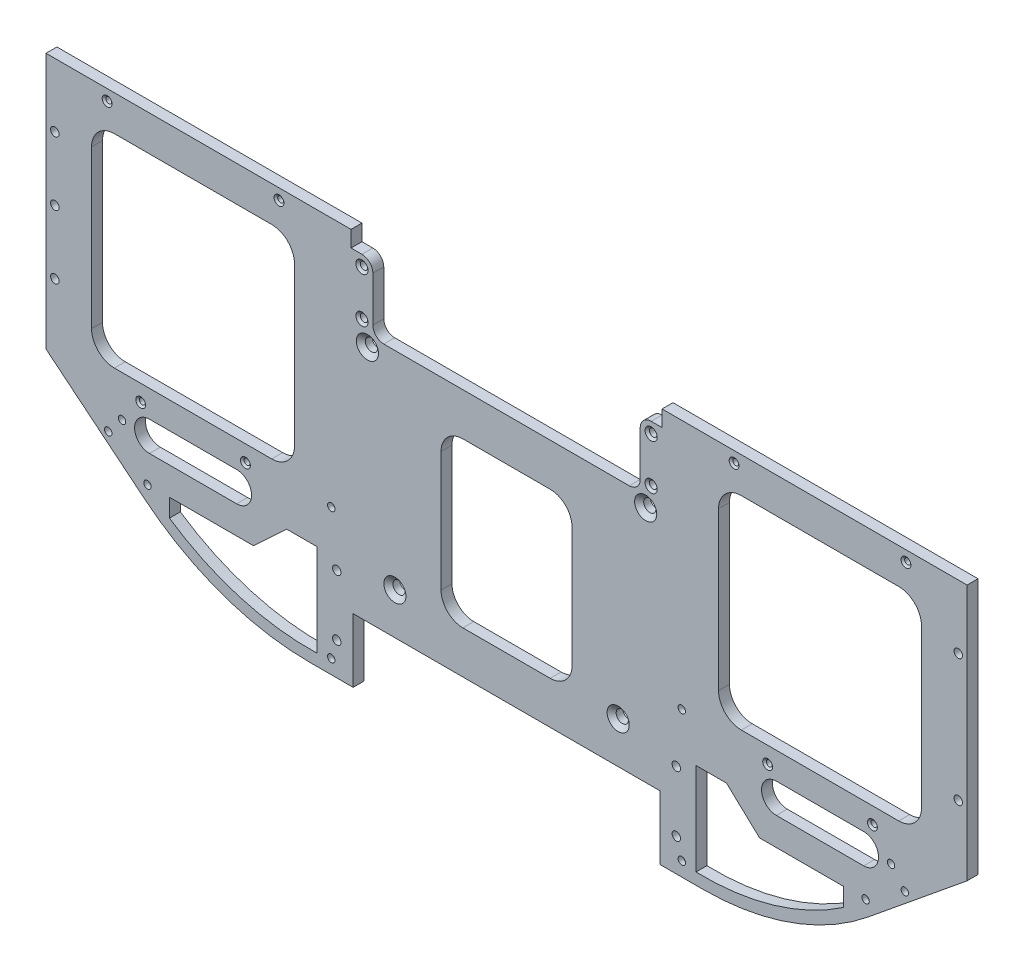
from build123d import *

# Parameters (mm, degrees)
BOSS_EXTRUDE1_DEPTH                                 = 6.35
CUT_EXTRUDE1_DEPTH                                  = 7.35
CSK_FOR_1_4_FLAT_HEAD_MACHINE_SCREW_100_D           = 7.14248
CSK_FOR_1_4_FLAT_HEAD_MACHINE_SCREW_100_DEPTH       = 6.35
CSK_FOR_1_4_FLAT_HEAD_MACHINE_SCREW_100_CSINK_D     = 12.8778
CSK_FOR_1_4_FLAT_HEAD_MACHINE_SCREW_100_CSINK_ANGLE = 100
CSK_FOR_4_FLAT_HEAD_MACHINE_SCREW_100_D             = 3.4544
CSK_FOR_4_FLAT_HEAD_MACHINE_SCREW_100_CSINK_D       = 5.715
CSK_FOR_4_FLAT_HEAD_MACHINE_SCREW_100_CSINK_ANGLE   = 100
CUT_EXTRUDE2_REACH                                  = 8.35
SKETCH7_W                                           = 178.5366
SKETCH7_H                                           = 37.1475
F_6_CLEARANCE_HOLE1_D                               = 4.3053
F_6_CLEARANCE_HOLE1_DEPTH                           = 6.35
F_6_PLASTIC_INSERT_AT_2_COUNT                       = 2
F_6_PLASTIC_INSERT_AT_2_PITCH                       = 112.229639339
F_6_PLASTIC_INSERT_AT_3_COUNT                       = 2
F_6_PLASTIC_INSERT_AT_3_PITCH                       = 114.9605422
F_6_PLASTIC_INSERT_AT_4_COUNT                       = 2
F_6_PLASTIC_INSERT_AT_4_PITCH                       = 313.747300742
F_6_PLASTIC_INSERT_AT_5_COUNT                       = 2
F_6_PLASTIC_INSERT_AT_5_PITCH                       = 312.75698938
F_6_PLASTIC_INSERT_AT_6_COUNT                       = 2
F_6_PLASTIC_INSERT_AT_6_PITCH                       = 417.83
F_6_CLEARANCE_HOLE2_D                               = 4.3053
CUT_EXTRUDE3_REACH                                  = 8.35
SKETCH55_W                                          = 12.7
SKETCH55_H                                          = 26.162975929
BOSS_EXTRUDE2_DEPTH                                 = 6.35
FILLET3_R                                           = 6.35
CSK_FOR_6_FLAT_HEAD_MACHINE_SCREW_100_D             = 4.3053
CSK_FOR_6_FLAT_HEAD_MACHINE_SCREW_100_CSINK_D       = 7.0866
CSK_FOR_6_FLAT_HEAD_MACHINE_SCREW_100_CSINK_ANGLE   = 100
SKETCH58_W                                          = 76.2
SKETCH58_H                                          = 95.25
CUT_EXTRUDE4_DEPTH                                  = 7.35
CUT_EXTRUDE5_DEPTH                                  = 7.35
CSK_FOR_8_FLAT_HEAD_MACHINE_SCREW_100_D             = 4.9149
CSK_FOR_8_FLAT_HEAD_MACHINE_SCREW_100_DEPTH         = 6.35
CSK_FOR_8_FLAT_HEAD_MACHINE_SCREW_100_CSINK_D       = 8.4328
CSK_FOR_8_FLAT_HEAD_MACHINE_SCREW_100_CSINK_ANGLE   = 100
FILLET4_R                                           = 12.7
CSK_FOR_6_FLAT_HEAD_MACHINE_SCREW_2_D               = 4.3053
CSK_FOR_6_FLAT_HEAD_MACHINE_SCREW_2_DEPTH           = 6.35
CSK_FOR_6_FLAT_HEAD_MACHINE_SCREW_2_CSINK_D         = 7.0866
CSK_FOR_6_FLAT_HEAD_MACHINE_SCREW_2_CSINK_ANGLE     = 100


with BuildPart() as part:
    # Sketch1 → Boss-Extrude1 (new body)
    with BuildSketch(Plane.XY):
        with BuildLine():
            Line((-296.70375, -233.3625), (-68.10375, -233.3625))
            ThreePointArc((-68.10375, -233.3625), (-16.943813494, -224.518833531), (28.278571633, -199.014217805))
            Line((28.278571633, -199.014217805), (95.09125, -144.4625))
            ThreePointArc((95.09125, -144.4625), (116.399773511, -117.921148224), (131.28625, -87.3125))
            Line((131.28625, -87.3125), (131.28625, 23.8125))
            Line((131.28625, 23.8125), (85.56625, 23.8125))
            Line((85.56625, 23.8125), (85.56625, -3.175))
            Line((85.56625, -3.175), (-131.60375, -3.175))
            Line((-131.60375, -3.175), (-131.60375, 20.5105))
            Line((-131.60375, 20.5105), (-233.20375, 20.5105))
            Line((-233.20375, 20.5105), (-233.20375, -3.175))
            Line((-233.20375, -3.175), (-450.37375, -3.175))
            Line((-450.37375, -3.175), (-450.37375, -20.955))
            Line((-450.37375, -20.955), (-496.09375, -20.955))
            Line((-496.09375, -20.955), (-496.09375, -87.3125))
            ThreePointArc((-496.09375, -87.3125), (-481.207273511, -117.921148224), (-459.89875, -144.4625))
            Line((-459.89875, -144.4625), (-393.086071633, -199.014217805))
            ThreePointArc((-393.086071633, -199.014217805), (-347.863686506, -224.518833531), (-296.70375, -233.3625))
        make_face()
    extrude(amount=BOSS_EXTRUDE1_DEPTH)

    # Sketch2 → Cut-Extrude1 (cut, through all)
    with BuildSketch(Plane.XY.offset(6.35)):
        with BuildLine():
            Line((-423.8625, -37.078640371), (-423.8625, -128.656359629))
            ThreePointArc((-423.8625, -128.656359629), (-419.976937445, -138.036937445), (-410.596359629, -141.9225))
            Line((-410.596359629, -141.9225), (-319.018640371, -141.9225))
            ThreePointArc((-319.018640371, -141.9225), (-309.638062555, -138.036937445), (-305.7525, -128.656359629))
            Line((-305.7525, -128.656359629), (-305.7525, -37.078640371))
            ThreePointArc((-305.7525, -37.078640371), (-309.638062555, -27.698062555), (-319.018640371, -23.8125))
            Line((-319.018640371, -23.8125), (-410.596359629, -23.8125))
            ThreePointArc((-410.596359629, -23.8125), (-419.976937445, -27.698062555), (-423.8625, -37.078640371))
        make_face()
        with BuildLine():
            Line((-292.63975, -172.976918908), (-292.63975, -226.638323184))
            ThreePointArc((-292.63975, -226.638323184), (-337.571759927, -220.847335922), (-378.554315308, -201.537980571))
            Line((-378.554315308, -201.537980571), (-378.554315308, -190.97625))
            Line((-378.554315308, -190.97625), (-329.636065959, -190.97625))
            Line((-329.636065959, -190.97625), (-310.347063169, -172.976918908))
            Line((-310.347063169, -172.976918908), (-292.63975, -172.976918908))
        make_face()
        with BuildLine():
            Line((-339.407500187, -174.752000205), (-390.207500187, -174.752000205))
            ThreePointArc((-390.207500187, -174.752000205), (-398.843500187, -166.116000205), (-390.207500187, -157.480000205))
            Line((-390.207500187, -157.480000205), (-339.407500187, -157.480000205))
            ThreePointArc((-339.407500187, -157.480000205), (-330.771500187, -166.116000205), (-339.407500187, -174.752000205))
        make_face()
        with BuildLine():
            Line((-25.399999813, -174.752000205), (25.400000187, -174.752000205))
            ThreePointArc((25.400000187, -174.752000205), (34.036000187, -166.116000205), (25.400000187, -157.480000205))
            Line((25.400000187, -157.480000205), (-25.399999813, -157.480000205))
            ThreePointArc((-25.399999813, -157.480000205), (-34.035999813, -166.116000205), (-25.399999813, -174.752000205))
        make_face()
        with BuildLine():
            Line((13.746815308, -201.537980571), (13.746815308, -190.97625))
            Line((13.746815308, -190.97625), (-35.171434041, -190.97625))
            Line((-35.171434041, -190.97625), (-54.460436831, -172.976918908))
            Line((-54.460436831, -172.976918908), (-72.16775, -172.976918908))
            Line((-72.16775, -172.976918908), (-72.16775, -226.638323184))
            ThreePointArc((-72.16775, -226.638323184), (-27.235740073, -220.847335922), (13.746815308, -201.537980571))
        make_face()
        with BuildLine():
            Line((45.788859629, -141.9225), (-45.788859629, -141.9225))
            ThreePointArc((-45.788859629, -141.9225), (-55.169437445, -138.036937445), (-59.055, -128.656359629))
            Line((-59.055, -128.656359629), (-59.055, -37.078640371))
            ThreePointArc((-59.055, -37.078640371), (-55.169437445, -27.698062555), (-45.788859629, -23.8125))
            Line((-45.788859629, -23.8125), (45.788859629, -23.8125))
            ThreePointArc((45.788859629, -23.8125), (55.169437445, -27.698062555), (59.055, -37.078640371))
            Line((59.055, -37.078640371), (59.055, -128.656359629))
            ThreePointArc((59.055, -128.656359629), (55.169437445, -138.036937445), (45.788859629, -141.9225))
        make_face()
    extrude(amount=-CUT_EXTRUDE1_DEPTH, mode=Mode.SUBTRACT)

    # CSK for 1/4 Flat Head Machine Screw (100)1
    with Locations(Plane.XY.offset(6.35)):
        with Locations((-247.36425, -172.085), (-263.36625, -57.785), (-117.44325, -172.085), (-101.44125, -57.785)):
            CounterSinkHole(CSK_FOR_1_4_FLAT_HEAD_MACHINE_SCREW_100_D / 2, CSK_FOR_1_4_FLAT_HEAD_MACHINE_SCREW_100_CSINK_D / 2, depth=CSK_FOR_1_4_FLAT_HEAD_MACHINE_SCREW_100_DEPTH, counter_sink_angle=CSK_FOR_1_4_FLAT_HEAD_MACHINE_SCREW_100_CSINK_ANGLE)

    # CSK for #4 Flat Head Machine Screw (100)1 (through all)
    with Locations(Plane.XY.offset(6.35)):
        with Locations((-334.327500124, -151.530549932), (-395.287499843, -151.53054989), (-314.801250003, -9.525000088), (-414.813749771, -9.52500002), (30.479999876, -151.530549932), (-30.479999843, -151.53054989), (50.006249997, -9.525000088), (-50.006249771, -9.52500002)):
            CounterSinkHole(CSK_FOR_4_FLAT_HEAD_MACHINE_SCREW_100_D / 2, CSK_FOR_4_FLAT_HEAD_MACHINE_SCREW_100_CSINK_D / 2, counter_sink_angle=CSK_FOR_4_FLAT_HEAD_MACHINE_SCREW_100_CSINK_ANGLE)

    # Sketch7 → Cut-Extrude2 (cut, up to next)
    with BuildSketch(Plane.XY.offset(6.35), mode=Mode.PRIVATE) as cut_extrude2_sk1:
        with Locations((-182.40375, -214.78875)):
            Rectangle(SKETCH7_W, SKETCH7_H)
    cut_extrude2_tool1 = extrude(cut_extrude2_sk1.sketch, amount=-CUT_EXTRUDE2_REACH, mode=Mode.PRIVATE) & part.part
    add(cut_extrude2_tool1.solids().sort_by_distance((-182.40375, -214.78875, 6.35))[0], mode=Mode.SUBTRACT)

    # #6 Clearance Hole1
    with Locations(Plane(origin=(-452.317147347, -175.564262538, 0), x_dir=(-1, 0, 0), z_dir=(0, 0, -1))):
        with Locations((-60.998397348, -15.475487462), (-167.932397348, -49.543237462), (-167.932397348, 26.726952124), (-371.894397347, 26.726952124), (-371.894397347, -49.543237462), (-478.828397347, -15.475487462)):
            Hole(F_6_CLEARANCE_HOLE1_D / 2, depth=F_6_CLEARANCE_HOLE1_DEPTH)

    # Sketch51 → #6 Plastic Insert (revolve, cut)
    with BuildSketch(Plane(origin=(-391.31875, -191.03975, 0), x_dir=(0, 1, 0), z_dir=(1, 0, 0))):
        Polygon((0, 0), (0, 3.81), (2.5273, 3.81), (2.6543, 0), align=None)
    f_6_plastic_insert = revolve(axis=Axis((-391.31875, -191.03975, 110), (0, 0, -1)), mode=Mode.SUBTRACT)

    # #6 Plastic Insert at 2: #6 Plastic Insert ×2
    with Locations(*[Vector(0.952814253, -0.303553947, 0) * (i * F_6_PLASTIC_INSERT_AT_2_PITCH) for i in range(1, F_6_PLASTIC_INSERT_AT_2_COUNT)]):
        add(f_6_plastic_insert, mode=Mode.SUBTRACT)

    # #6 Plastic Insert at 3: #6 Plastic Insert ×2
    with Locations(*[Vector(0.930180025, 0.367103693, 0) * (i * F_6_PLASTIC_INSERT_AT_3_PITCH) for i in range(1, F_6_PLASTIC_INSERT_AT_3_COUNT)]):
        add(f_6_plastic_insert, mode=Mode.SUBTRACT)

    # #6 Plastic Insert at 4: #6 Plastic Insert ×2
    with Locations(*[Vector(0.990912111, 0.134510925, 0) * (i * F_6_PLASTIC_INSERT_AT_4_PITCH) for i in range(1, F_6_PLASTIC_INSERT_AT_4_COUNT)]):
        add(f_6_plastic_insert, mode=Mode.SUBTRACT)

    # #6 Plastic Insert at 5: #6 Plastic Insert ×2
    with Locations(*[Vector(0.994049727, -0.108927222, 0) * (i * F_6_PLASTIC_INSERT_AT_5_PITCH) for i in range(1, F_6_PLASTIC_INSERT_AT_5_COUNT)]):
        add(f_6_plastic_insert, mode=Mode.SUBTRACT)

    # #6 Plastic Insert at 6: #6 Plastic Insert ×2
    with Locations(*[(i * F_6_PLASTIC_INSERT_AT_6_PITCH, 0, 0) for i in range(1, F_6_PLASTIC_INSERT_AT_6_COUNT)]):
        add(f_6_plastic_insert, mode=Mode.SUBTRACT)

    # #6 Clearance Hole2 (through all)
    with Locations(Plane(origin=(0, 0, 0), x_dir=(-1, 0, 0), z_dir=(0, 0, -1))):
        with Locations((459.51775, -126.1745), (479.90125, -91.8845), (486.50525, -36.449), (-94.71025, -126.1745), (-121.95175, -83.6295), (-98.26625, 15.875)):
            Hole(F_6_CLEARANCE_HOLE2_D / 2)

    # Sketch54 → Cut-Extrude3 (cut, up to next)
    with BuildSketch(Plane.XY.offset(6.35), mode=Mode.PRIVATE) as cut_extrude3_sk1:
        Polygon((-272.89125, -38.735), (-260.19125, -38.735), (-260.19125, -51.435), (-104.61625, -51.435), (-104.61625, -38.735), (-91.91625, -38.735), (-91.91625, 22.098), (-272.89125, 22.098), align=None)
    cut_extrude3_tool1 = extrude(cut_extrude3_sk1.sketch, amount=-CUT_EXTRUDE3_REACH, mode=Mode.PRIVATE) & part.part
    add(cut_extrude3_tool1.solids().sort_by_distance((-182.40375, -13.912881, 6.35))[0], mode=Mode.SUBTRACT)

    # Sketch55 → Boss-Extrude2 (add, through all)
    with BuildSketch(Plane.XY.offset(6.35)):
        with Locations((-98.26625, -25.653512036)):
            Rectangle(SKETCH55_W, SKETCH55_H)
        with Locations((-266.54125, -25.653512036)):
            Rectangle(SKETCH55_W, SKETCH55_H)
    extrude(amount=-BOSS_EXTRUDE2_DEPTH)

    # Fillet3
    fillet3_edges = [part.edges().sort_by_distance(p)[0] for p in [
        (-104.61625, -51.435, 3.175),
        (-260.19125, -51.435, 3.175),
        (-104.61625, -12.572024071, 3.175),
        (-260.19125, -12.572024071, 3.175),
    ]]
    fillet(fillet3_edges, radius=FILLET3_R)

    # CSK for _6 Flat Head Machine Screw _100 (through all)
    with Locations(Plane.XY.offset(6.35)):
        with Locations((-266.54125, -18.922024071), (-98.26625, -18.922024071), (-98.26625, -45.180737964), (-266.54125, -45.180737964)):
            CounterSinkHole(CSK_FOR_6_FLAT_HEAD_MACHINE_SCREW_100_D / 2, CSK_FOR_6_FLAT_HEAD_MACHINE_SCREW_100_CSINK_D / 2, counter_sink_angle=CSK_FOR_6_FLAT_HEAD_MACHINE_SCREW_100_CSINK_ANGLE)

    # Sketch58 → Cut-Extrude4 (cut, through all)
    with BuildSketch(Plane.XY.offset(6.35)):
        with Locations((-182.40375, -123.825)):
            Rectangle(SKETCH58_W, SKETCH58_H)
    extrude(amount=-CUT_EXTRUDE4_DEPTH, mode=Mode.SUBTRACT)

    # Sketch60 → Cut-Extrude5 (cut, through all)
    with BuildSketch(Plane.XY.offset(6.35)):
        with BuildLine():
            Line((85.56625, 23.8125), (85.56625, -152.239543591))
            Line((85.56625, -152.239543591), (95.09125, -144.4625))
            ThreePointArc((95.09125, -144.4625), (116.399773511, -117.921148224), (131.28625, -87.3125))
            Line((131.28625, -87.3125), (131.28625, 23.8125))
            Line((131.28625, 23.8125), (85.56625, 23.8125))
        make_face()
        with BuildLine():
            Line((-450.37375, -20.955), (-496.09375, -20.955))
            Line((-496.09375, -20.955), (-496.09375, -87.3125))
            ThreePointArc((-496.09375, -87.3125), (-481.207273511, -117.921148224), (-459.89875, -144.4625))
            Line((-459.89875, -144.4625), (-450.37375, -152.239543591))
            Line((-450.37375, -152.239543591), (-450.37375, -20.955))
        make_face()
    extrude(amount=-CUT_EXTRUDE5_DEPTH, mode=Mode.SUBTRACT)

    # CSK for #8 Flat Head Machine Screw (100)2
    with Locations(Plane(origin=(0, 0, 0), x_dir=(-1, 0, 0), z_dir=(0, 0, -1))):
        with Locations((281.19705, -214.3125), (281.19705, -179.105836743), (445.23025, -77.214725701), (445.23025, -40.194862851), (445.23025, -114.234588552), (-80.42275, -114.234588552), (-80.42275, -40.194862851), (83.61045, -179.105836743), (83.61045, -214.3125)):
            CounterSinkHole(CSK_FOR_8_FLAT_HEAD_MACHINE_SCREW_100_D / 2, CSK_FOR_8_FLAT_HEAD_MACHINE_SCREW_100_CSINK_D / 2, depth=CSK_FOR_8_FLAT_HEAD_MACHINE_SCREW_100_DEPTH, counter_sink_angle=CSK_FOR_8_FLAT_HEAD_MACHINE_SCREW_100_CSINK_ANGLE)

    # Fillet4
    fillet4_edges = [part.edges().sort_by_distance(p)[0] for p in [
        (-220.50375, -171.45, 3.175),
        (-220.50375, -76.2, 3.175),
        (-144.30375, -76.2, 3.175),
        (-144.30375, -171.45, 3.175),
    ]]
    fillet(fillet4_edges, radius=FILLET4_R)

    # CSK for _6 Flat Head Machine Screw _ 2
    with Locations(Plane(origin=(0, 0, 0), x_dir=(-1, 0, 0), z_dir=(0, 0, -1))):
        with Locations((414.160403417, -175.658955235), (406.128271665, -165.821533849), (-41.318287119, -165.823323003), (-49.350418871, -175.660744388)):
            CounterSinkHole(CSK_FOR_6_FLAT_HEAD_MACHINE_SCREW_2_D / 2, CSK_FOR_6_FLAT_HEAD_MACHINE_SCREW_2_CSINK_D / 2, depth=CSK_FOR_6_FLAT_HEAD_MACHINE_SCREW_2_DEPTH, counter_sink_angle=CSK_FOR_6_FLAT_HEAD_MACHINE_SCREW_2_CSINK_ANGLE)


solid = part.part
